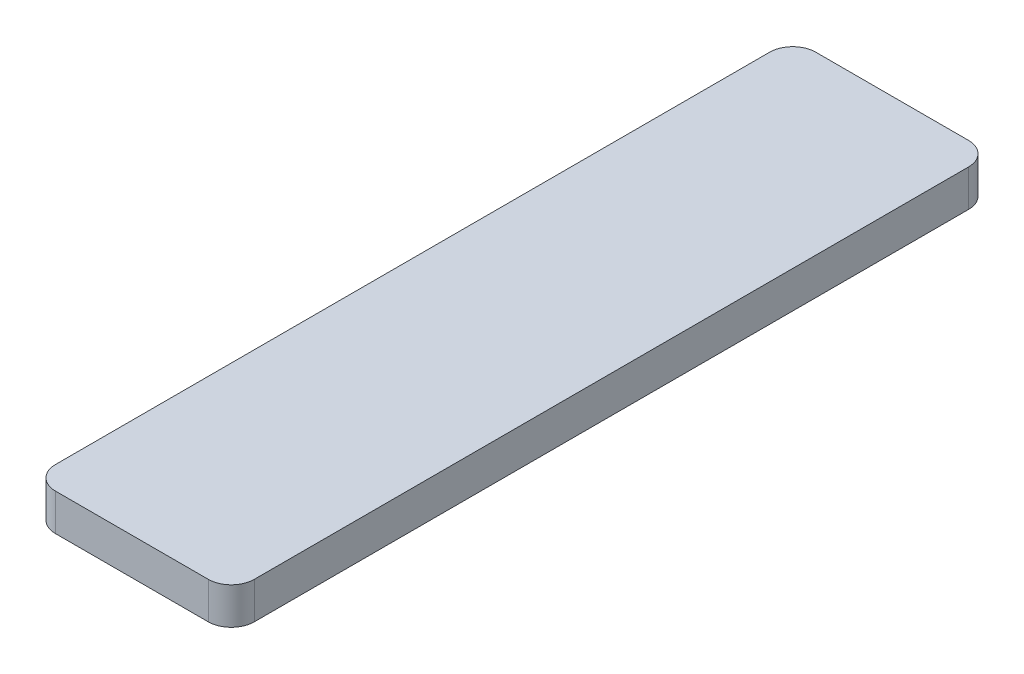
from build123d import *

# Parameters (mm, degrees)
SKETCH2_W           = 8.636
SKETCH2_H           = 33.02
BOSS_EXTRUDE1_DEPTH = 1.6
FILLET1_R           = 1


with BuildPart() as part:
    # Sketch2 → Boss-Extrude1 (new body)
    with BuildSketch(Plane(origin=(0, 0, 0), x_dir=(1, 0, 0), z_dir=(0, 1, 0))):
        with Locations((-100.196877437, -32.55713814)):
            Rectangle(SKETCH2_W, SKETCH2_H)
    extrude(amount=BOSS_EXTRUDE1_DEPTH)

    # Fillet1
    fillet1_edges = [part.edges().sort_by_distance(p)[0] for p in [
        (-95.878877437, 0.8, 49.06713814),
        (-104.514877437, 0.8, 49.06713814),
        (-104.514877437, 0.8, 16.04713814),
        (-95.878877437, 0.8, 16.04713814),
    ]]
    fillet(fillet1_edges, radius=FILLET1_R)


solid = part.part
